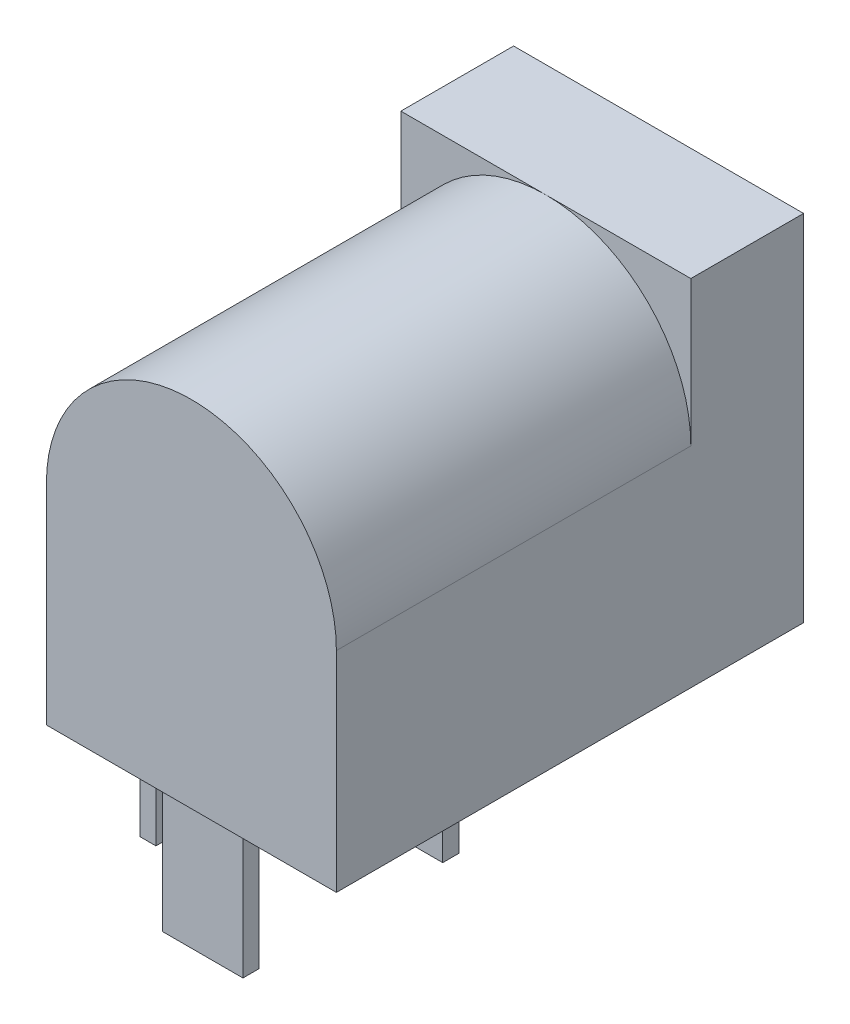
from build123d import *

# Parameters (mm, degrees)
SKETCH1_W          = 9
SKETCH1_H          = 11
EXTRUDE1_DEPTH     = 14.5
SKETCH2_W          = 2.5
SKETCH2_H          = 0.5
SKETCH2_W_2        = 0.5
SKETCH2_H_2        = 2.5
EXTRUDE2_DEPTH     = 4.1
CUT_EXTRUDE1_DEPTH = 11
SKETCH4_R          = 2.1
CUT_EXTRUDE2_DEPTH = 10


with BuildPart() as part:
    # Sketch1 → Extrude1 (new body)
    with BuildSketch(Plane.XY):
        with Locations((0, 5.5)):
            Rectangle(SKETCH1_W, SKETCH1_H)
    extrude(amount=EXTRUDE1_DEPTH)

    # Sketch2 → Extrude2 (add)
    with BuildSketch(Plane.XZ):
        with Locations((0, 13.9)):
            Rectangle(SKETCH2_W, SKETCH2_H)
        with Locations((0, 7.7)):
            Rectangle(SKETCH2_W, SKETCH2_H)
        with Locations((-3.9, 10.7)):
            Rectangle(SKETCH2_W_2, SKETCH2_H_2)
    extrude(amount=EXTRUDE2_DEPTH)

    # Sketch3 → Cut-Extrude1 (cut)
    with BuildSketch(Plane.XY.offset(14.5)):
        with BuildLine():
            Line((4.5, 6.5), (5.915924782, 6.5))
            Line((5.915924782, 6.5), (5.915924782, 12.170720509))
            Line((5.915924782, 12.170720509), (-5.281401608, 12.170720509))
            Line((-5.281401608, 12.170720509), (-5.281401608, 6.5))
            Line((-5.281401608, 6.5), (-4.5, 6.5))
            ThreePointArc((-4.5, 6.5), (0, 11), (4.5, 6.5))
        make_face()
    extrude(amount=-CUT_EXTRUDE1_DEPTH, mode=Mode.SUBTRACT)

    # Sketch4 → Cut-Extrude2 (cut)
    with BuildSketch(Plane(origin=(0, 0, 0), x_dir=(-1, 0, 0), z_dir=(0, 0, -1))):
        with Locations((0, 6.5)):
            Circle(SKETCH4_R)
    extrude(amount=-CUT_EXTRUDE2_DEPTH, mode=Mode.SUBTRACT)


solid = part.part
